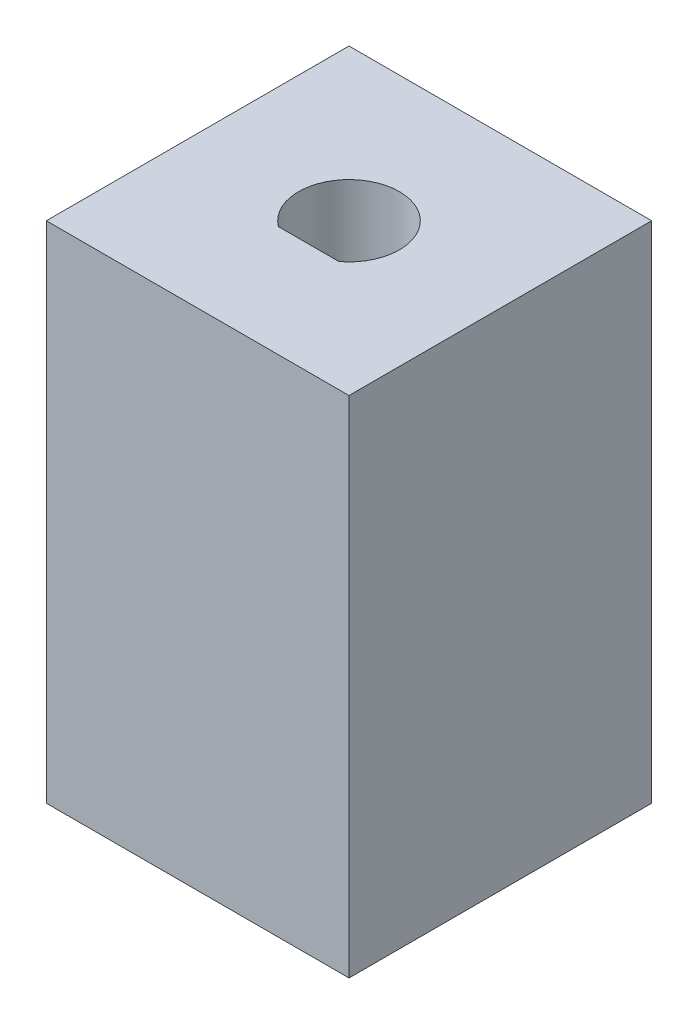
from build123d import *

# Parameters (mm, degrees)
SKETCH1_W           = 15
SKETCH1_H           = 15
BOSS_EXTRUDE1_DEPTH = 25
CUT_EXTRUDE1_DEPTH  = 20


with BuildPart() as part:
    # Sketch1 → Boss-Extrude1 (new body)
    with BuildSketch(Plane(origin=(0, 0, 0), x_dir=(1, 0, 0), z_dir=(0, 1, 0))):
        with Locations((7.5, 7.5)):
            Rectangle(SKETCH1_W, SKETCH1_H)
    extrude(amount=BOSS_EXTRUDE1_DEPTH)

    # Sketch2 → Cut-Extrude1 (cut)
    with BuildSketch(Plane(origin=(0, 25, 0), x_dir=(1, 0, 0), z_dir=(0, 1, 0))):
        with BuildLine():
            Line((6, 5.5), (9, 5.5))
            ThreePointArc((9, 5.5), (7.5, 10), (6, 5.5))
        make_face()
    extrude(amount=-CUT_EXTRUDE1_DEPTH, mode=Mode.SUBTRACT)


solid = part.part
